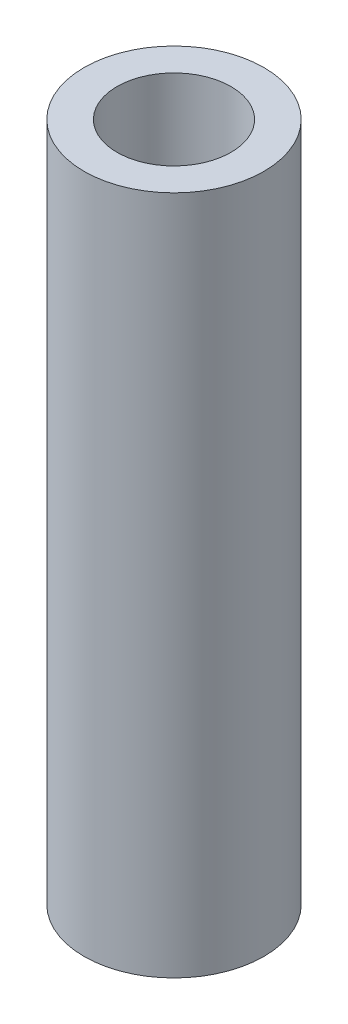
from build123d import *

# Parameters (mm, degrees)
SKETCH1_R               = 4.7625
SKETCH1_R_2             = 3.018976491
BOSS_EXTRUDE1_DEPTH     = 65
SKETCH5_W               = 36.473052953
SKETCH5_H               = 81.397778837
CUT_EXTRUDE2_DEPTH      = 5.7625
CUT_EXTRUDE2_DEPTH_BACK = 5.7625
SKETCH6_W               = 37.230077322
SKETCH6_H               = 44.032609969
CUT_EXTRUDE3_DEPTH      = 5.7625
CUT_EXTRUDE3_DEPTH_BACK = 5.7625


with BuildPart() as part:
    # Sketch1 → Boss-Extrude1 (new body, symmetric)
    with BuildSketch(Plane(origin=(0, 0, 0), x_dir=(1, 0, 0), z_dir=(0, 1, 0))):
        Circle(SKETCH1_R)
        Circle(SKETCH1_R_2, mode=Mode.SUBTRACT)
    extrude(amount=BOSS_EXTRUDE1_DEPTH, both=True)

    # Sketch5 → Cut-Extrude2 (cut, two sides)
    with BuildSketch(Plane(origin=(0, 0, 0), x_dir=(0, 0, -1), z_dir=(1, 0, 0))) as cut_extrude2_sk:
        with Locations((-2.67750977, 45.698889419)):
            Rectangle(SKETCH5_W, SKETCH5_H)
    extrude(amount=CUT_EXTRUDE2_DEPTH, mode=Mode.SUBTRACT)
    extrude(cut_extrude2_sk.sketch, amount=-CUT_EXTRUDE2_DEPTH_BACK, mode=Mode.SUBTRACT)

    # Sketch6 → Cut-Extrude3 (cut, two sides)
    with BuildSketch(Plane(origin=(0, 0, 0), x_dir=(0, 0, -1), z_dir=(1, 0, 0))) as cut_extrude3_sk:
        with Locations((-3.171451031, -53.016304985)):
            Rectangle(SKETCH6_W, SKETCH6_H)
    extrude(amount=CUT_EXTRUDE3_DEPTH, mode=Mode.SUBTRACT)
    extrude(cut_extrude3_sk.sketch, amount=-CUT_EXTRUDE3_DEPTH_BACK, mode=Mode.SUBTRACT)


solid = part.part
